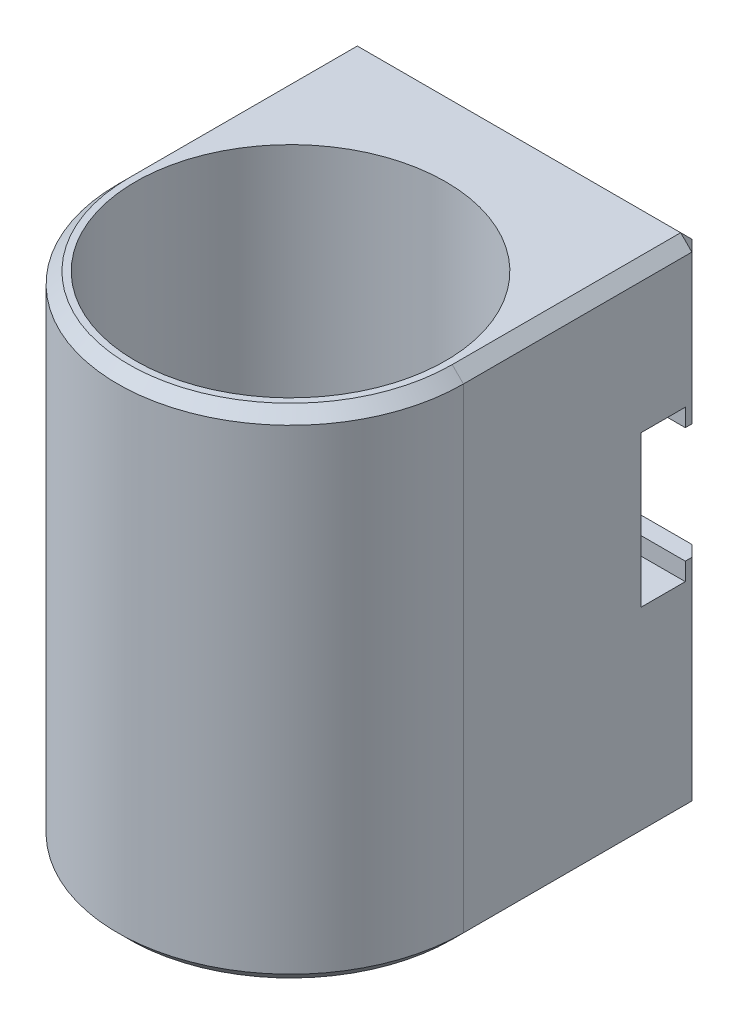
from build123d import *

# Parameters (mm, degrees)
SKETCH1_R           = 13.85
BOSS_EXTRUDE1_DEPTH = 44.45
SKETCH2_R           = 15.08125
BOSS_EXTRUDE2_DEPTH = 1.5875
CUT_EXTRUDE1_DEPTH  = 31.875
CHAMFER1_SIZE       = 1


with BuildPart() as part:
    # Sketch1 → Boss-Extrude1 (new body)
    with BuildSketch(Plane(origin=(0, 0, 0), x_dir=(1, 0, 0), z_dir=(0, 1, 0))):
        with BuildLine():
            Line((-15.4375, 0), (-15.4375, 21.4))
            Line((-15.4375, 21.4), (15.4375, 21.4))
            Line((15.4375, 21.4), (15.4375, 0))
            ThreePointArc((15.4375, 0), (0, -15.4375), (-15.4375, 0))
        make_face()
        Circle(SKETCH1_R, mode=Mode.SUBTRACT)
    extrude(amount=BOSS_EXTRUDE1_DEPTH)

    # Sketch2 → Boss-Extrude2 (add)
    with BuildSketch(Plane.XZ):
        Circle(SKETCH2_R)
    extrude(amount=-BOSS_EXTRUDE2_DEPTH)

    # Sketch3 → Cut-Extrude1 (cut, through all)
    with BuildSketch(Plane(origin=(15.4375, 0, 0), x_dir=(0, 0, -1), z_dir=(1, 0, 0))):
        Polygon((21.4, 30.1625), (19.8125, 30.1625), (19.8125, 31.75), (15.84375, 31.75), (15.84375, 18.25625), (19.8125, 18.25625), (19.8125, 19.84375), (21.4, 19.84375), align=None)
    extrude(amount=-CUT_EXTRUDE1_DEPTH, mode=Mode.SUBTRACT)

    # Chamfer1
    chamfer1_edges = [part.edges().sort_by_distance(p)[0] for p in [
        (0, 44.45, -21.4),
        (-15.4375, 44.45, -10.7),
        (-15.4375, 9.921875, -21.4),
        (15.4375, 9.921875, -21.4),
        (0, 44.45, 15.4375),
        (-15.4375, 0, -10.7),
        (0, 0, -21.4),
        (15.4375, 0, -10.7),
        (0, 0, 15.4375),
        (15.4375, 44.45, -10.7),
        (-15.4375, 37.30625, -21.4),
        (15.4375, 37.30625, -21.4),
    ]]
    chamfer(chamfer1_edges, length=CHAMFER1_SIZE)


solid = part.part
